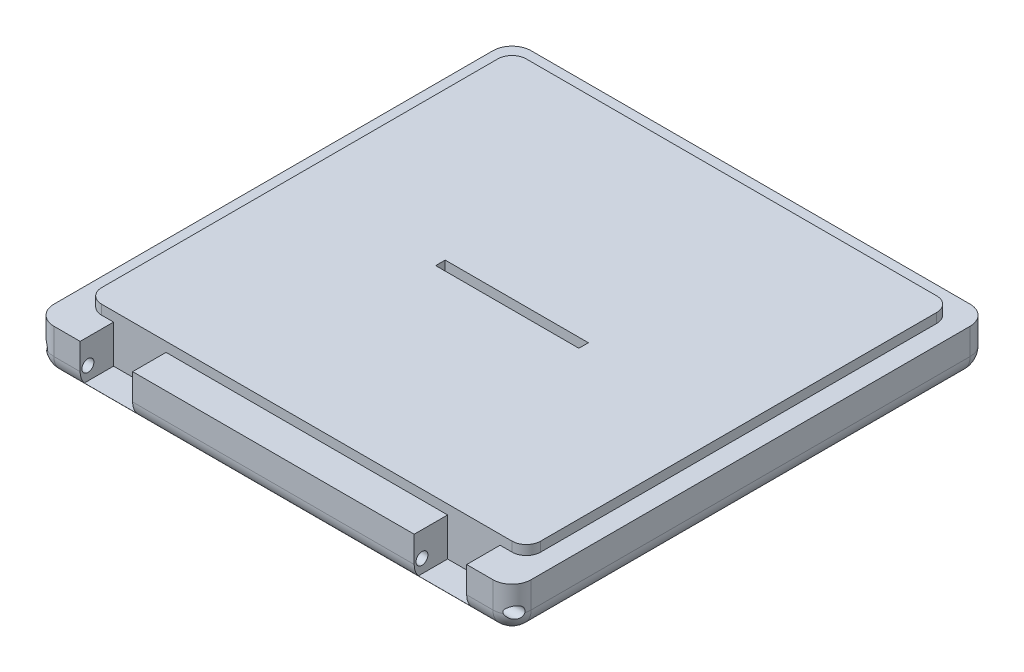
from build123d import *

# Parameters (mm, degrees)
SKETCH_1_W               = 100
SKETCH_1_H               = 100
EXTRUDE_1_DEPTH          = 9.5
FILLET_1_R               = 4
SKETCH_3_W               = 92
SKETCH_3_H               = 89
EXTRUDE_2_DEPTH          = 2
FILLET_2_R               = 3
SKETCH_2_W               = 11
SKETCH_2_H               = 7
CUT_EXTRUDE_1_DEPTH      = 8
SKETCH_4_R               = 1.25
CUT_EXTRUDE_2_DEPTH      = 91.5
CUT_EXTRUDE_2_DEPTH_BACK = 10.5
SKETCH_5_W               = 30
SKETCH_5_H               = 2
CUT_EXTRUDE_3_DEPTH      = 12.5


with BuildPart() as part:
    # Эскиз1 → Бобышка-Вытянуть1 (new body)
    with BuildSketch(Plane(origin=(0, 0, 0), x_dir=(1, 0, 0), z_dir=(0, 1, 0))):
        Rectangle(SKETCH_1_W, SKETCH_1_H)
    extrude(amount=EXTRUDE_1_DEPTH)

    # Скругление1
    fillet_1_edges = [part.edges().sort_by_distance(p)[0] for p in [
        (0, 0, 50),
        (-50, 0, 0),
        (0, 0, -50),
        (50, 0, 0),
        (50, 4.75, 50),
        (-50, 4.75, 50),
        (-50, 4.75, -50),
        (50, 4.75, -50),
    ]]
    fillet(fillet_1_edges, radius=FILLET_1_R)

    # Эскиз3 → Бобышка-Вытянуть2 (add)
    with BuildSketch(Plane(origin=(0, 9.5, 0), x_dir=(1, 0, 0), z_dir=(0, 1, 0))):
        with Locations((0, 1.5)):
            Rectangle(SKETCH_3_W, SKETCH_3_H)
    extrude(amount=EXTRUDE_2_DEPTH)

    # Скругление2
    fillet_2_edges = [part.edges().sort_by_distance(p)[0] for p in [
        (46, 10.5, 43),
        (46, 10.5, -46),
        (-46, 10.5, -46),
        (-46, 10.5, 43),
    ]]
    fillet(fillet_2_edges, radius=FILLET_2_R)

    # Эскиз2 → Вырез-Вытянуть1 (cut)
    with BuildSketch(Plane(origin=(0, 9.5, 0), x_dir=(1, 0, 0), z_dir=(0, 1, 0))):
        with Locations((35, -46.5)):
            Rectangle(SKETCH_2_W, SKETCH_2_H)
        with Locations((-35, -46.5)):
            Rectangle(SKETCH_2_W, SKETCH_2_H)
    extrude(amount=-CUT_EXTRUDE_1_DEPTH, mode=Mode.SUBTRACT)

    # Эскиз4 → Вырез-Вытянуть2 (cut, two sides)
    with BuildSketch(Plane(origin=(-40.5, 0, 0), x_dir=(0, 0, -1), z_dir=(1, 0, 0))) as cut_extrude_2_sk:
        with Locations((-48.37, 4.3)):
            Circle(SKETCH_4_R)
    extrude(amount=CUT_EXTRUDE_2_DEPTH, mode=Mode.SUBTRACT)
    extrude(cut_extrude_2_sk.sketch, amount=-CUT_EXTRUDE_2_DEPTH_BACK, mode=Mode.SUBTRACT)

    # Эскиз5 → Вырез-Вытянуть3 (cut, through all)
    with BuildSketch(Plane.XZ):
        Rectangle(SKETCH_5_W, SKETCH_5_H)
    extrude(amount=-CUT_EXTRUDE_3_DEPTH, mode=Mode.SUBTRACT)


solid = part.part
